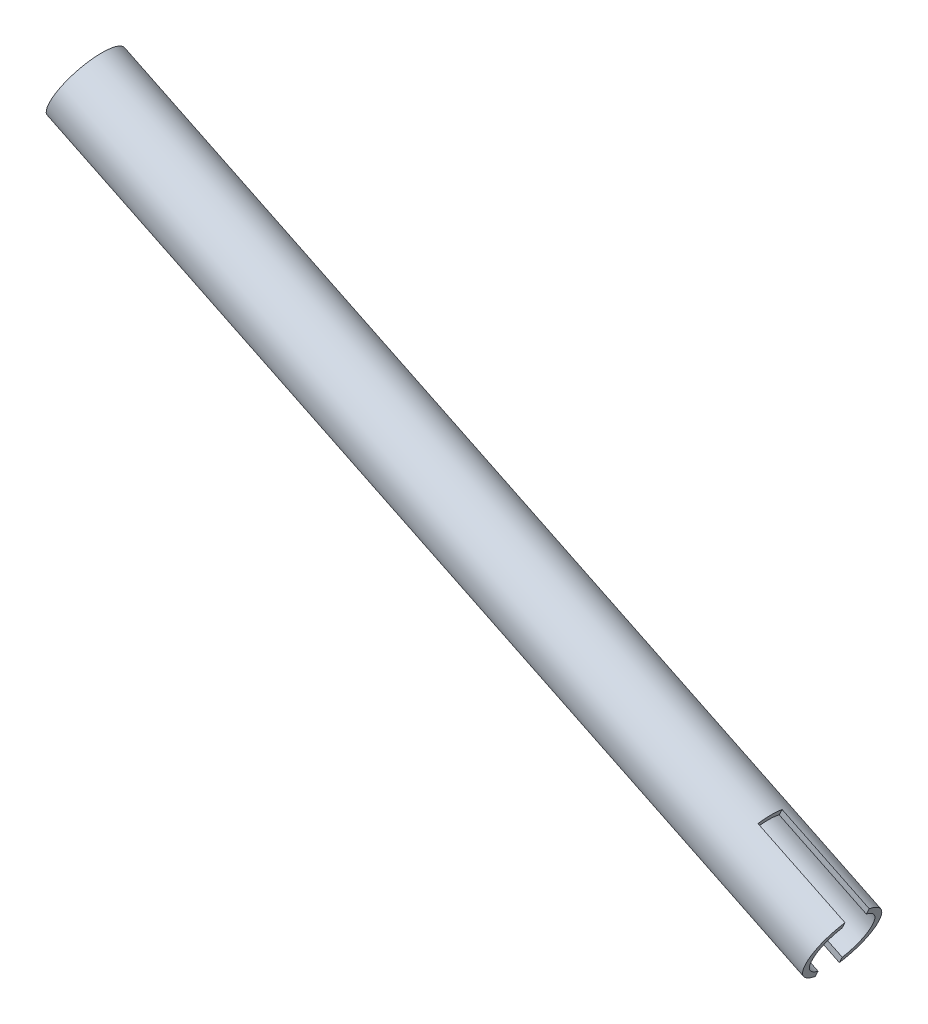
from build123d import *

# Parameters (mm, degrees)
CUT_EXTRUDE1_START = -3.175
CUT_EXTRUDE1_DEPTH = 6.35


with BuildPart() as part:
    # Sketch1 → Revolve1 (revolve)
    with BuildSketch(Plane.XY):
        Polygon((369.442161905, 123.802816275), (567.864710706, 27.346117543), (567.14289772, 25.861265021), (368.720348919, 122.317963753), align=None)
    revolve(axis=Axis((549.918417615, 44.825187693, 0), (0.89936555, -0.437197448, 0)))

    # Sketch2 → Cut-Extrude1 (cut)
    with BuildSketch(Plane.XY.offset(CUT_EXTRUDE1_START)):
        Polygon((552.627624135, 54.098993909), (575.471509095, 42.994178741), (567.14289772, 25.861265021), (544.299012759, 36.966080188), align=None)
    extrude(amount=CUT_EXTRUDE1_DEPTH, mode=Mode.SUBTRACT)


solid = part.part
